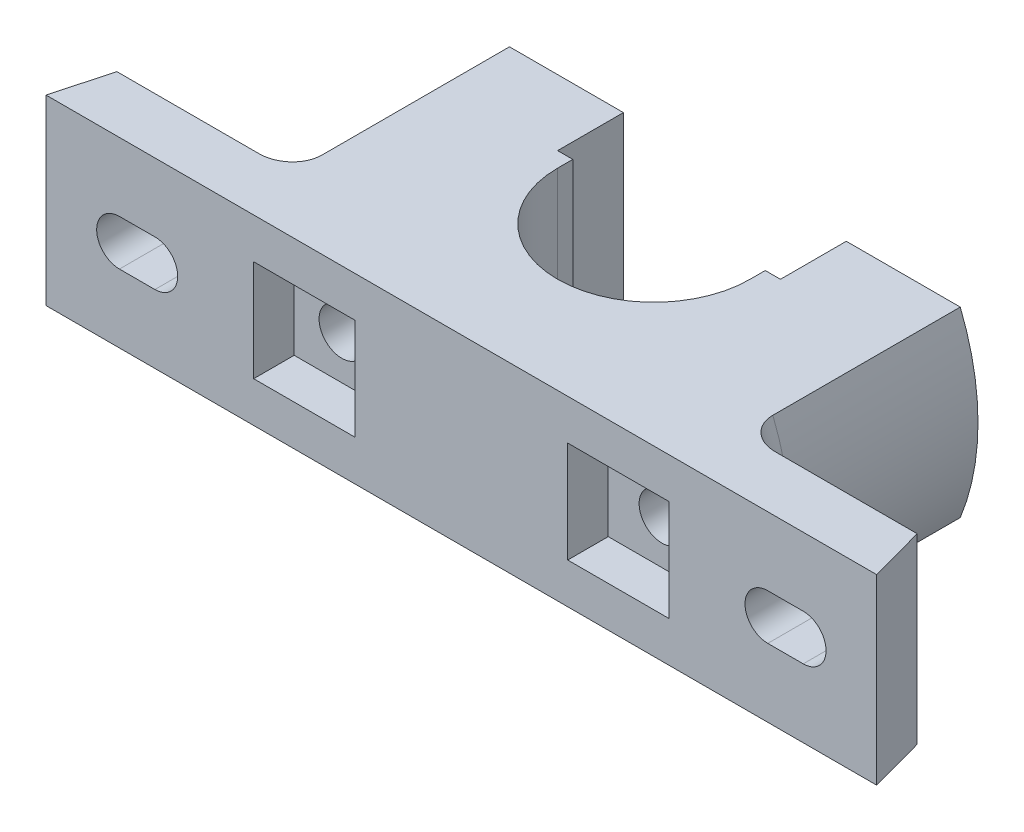
from build123d import *

# Parameters (mm, degrees)
BOSS_EXTRUDE1_DEPTH        = 18
SKETCH2_W                  = 20
SKETCH2_H                  = 20
CUT_EXTRUDE1_DEPTH         = 8
CUT_EXTRUDE2_DEPTH         = 11
F_10_0MM_DOWEL_HOLE3_D     = 6
F_10_0MM_DOWEL_HOLE3_DEPTH = 6
F_10_0MM_DOWEL_HOLE3_TIP   = 1.802581857
CUT_EXTRUDE4_DEPTH         = 43
FILLET1_R                  = 6
FILLET2_R                  = 6


with BuildPart() as part:
    # Sketch1 → Boss-Extrude1 (new body, symmetric)
    with BuildSketch(Plane(origin=(0, 0, 0), x_dir=(1, 0, 0), z_dir=(0, 1, 0))):
        with BuildLine():
            Line((-82, 0), (82, 0))
            Line((82, 0), (79, 11))
            Line((79, 11), (50, 11))
            Line((50, 11), (50, 54))
            Line((50, 54), (22, 54))
            Line((22, 54), (22, 41))
            Line((22, 41), (19, 41))
            Line((19, 41), (19, 38))
            ThreePointArc((19, 38), (0, 19), (-19, 38))
            Line((-19, 38), (-19, 41))
            Line((-19, 41), (-22, 41))
            Line((-22, 41), (-22, 54))
            Line((-22, 54), (-50, 54))
            Line((-50, 54), (-50, 11))
            Line((-50, 11), (-79, 11))
            Line((-79, 11), (-82, 0))
        make_face()
    extrude(amount=BOSS_EXTRUDE1_DEPTH, both=True)

    # Sketch2 → Cut-Extrude1 (cut)
    with BuildSketch(Plane.XY):
        with Locations((-31, 0)):
            Rectangle(SKETCH2_W, SKETCH2_H)
    cut_extrude1 = extrude(amount=-CUT_EXTRUDE1_DEPTH, mode=Mode.SUBTRACT)

    # Sketch3 → Ø10.0mm Dowel Hole1 (revolve, cut)
    with BuildSketch(Plane(origin=(-31.595535199, -1.31069469, -8), x_dir=(0, -1, 0), z_dir=(1, 0, 0))):
        Polygon((0, 0), (0, 56.703872786), (4.5, 54), (4.5, 0), align=None)
    f_10_0mm_dowel_hole1 = revolve(axis=Axis((-31.595535199, -1.31069469, -1.65), (0, 0, -1)), mode=Mode.SUBTRACT)

    # Sketch5 → Cut-Extrude2 (cut)
    with BuildSketch(Plane(origin=(0, 0, -11), x_dir=(-1, 0, 0), z_dir=(0, 0, -1))):
        with BuildLine():
            Line((60.5, 4.5), (67.5, 4.5))
            ThreePointArc((67.5, 4.5), (72, 0), (67.5, -4.5))
            Line((67.5, -4.5), (60.5, -4.5))
            ThreePointArc((60.5, -4.5), (56, 0), (60.5, 4.5))
        make_face()
    cut_extrude2 = extrude(amount=-CUT_EXTRUDE2_DEPTH, mode=Mode.SUBTRACT)

    # Mirror5: Cut-Extrude1, Ø10.0mm Dowel Hole1, Cut-Extrude2 across plane
    add(cut_extrude1.mirror(Plane(origin=(0, 0, 0), x_dir=(0, 0, 1), z_dir=(1, 0, 0))), mode=Mode.SUBTRACT)
    add(f_10_0mm_dowel_hole1.mirror(Plane(origin=(0, 0, 0), x_dir=(0, 0, 1), z_dir=(1, 0, 0))), mode=Mode.SUBTRACT)
    add(cut_extrude2.mirror(Plane(origin=(0, 0, 0), x_dir=(0, 0, 1), z_dir=(1, 0, 0))), mode=Mode.SUBTRACT)

    # Ø10.0mm Dowel Hole3
    with Locations(Plane(origin=(-0.854458973, 0.680821322, -19.019222886), x_dir=(-0.998988269, 0, -0.044971525), z_dir=(0.044971525, 0, -0.998988269))):
        with Locations((0, 0)):
            Hole(F_10_0MM_DOWEL_HOLE3_D / 2, depth=F_10_0MM_DOWEL_HOLE3_DEPTH)
            with Locations((0, 0, -(F_10_0MM_DOWEL_HOLE3_DEPTH + F_10_0MM_DOWEL_HOLE3_TIP / 2))):  # 118° drill point
                Cone(0, F_10_0MM_DOWEL_HOLE3_D / 2, F_10_0MM_DOWEL_HOLE3_TIP, mode=Mode.SUBTRACT)

    # Sketch11 → Cut-Extrude4 (cut)
    with BuildSketch(Plane.XY.offset(-54)):
        with BuildLine():
            Line((-44.497190923, -18), (-50, -18))
            Line((-50, -18), (-50, 18))
            Line((-50, 18), (-44.497190923, 18))
            ThreePointArc((-44.497190923, 18), (-48, 0), (-44.497190923, -18))
        make_face()
    cut_extrude4 = extrude(amount=CUT_EXTRUDE4_DEPTH, mode=Mode.SUBTRACT)

    # Mirror6: Cut-Extrude4 across plane
    add(cut_extrude4.mirror(Plane(origin=(0, 0, 0), x_dir=(0, 0, 1), z_dir=(1, 0, 0))), mode=Mode.SUBTRACT)

    # Fillet1
    fillet1_edges = [part.edges().sort_by_distance(p)[0] for p in [
        (-48, 0, -11),
    ]]
    fillet(fillet1_edges, radius=FILLET1_R)

    # Fillet2
    fillet2_edges = [part.edges().sort_by_distance(p)[0] for p in [
        (48, 0, -11),
    ]]
    fillet(fillet2_edges, radius=FILLET2_R)


solid = part.part
